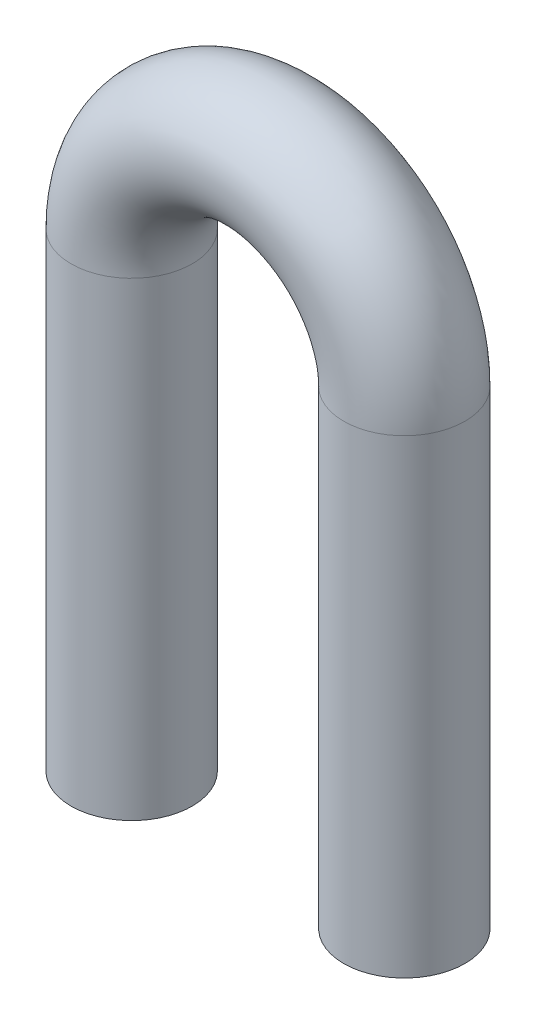
from build123d import *

# Parameters (mm, degrees)
SKETCH2_R = 2


with BuildPart() as part:
    # Sweep1: sweep along a path in Sketch1
    with BuildLine(Plane.XY) as sweep1_path:
        Line((0, 0), (0, 15.5))
        ThreePointArc((0, 15.5), (4.5, 20), (9, 15.5))
        Line((9, 15.5), (9, 0))
    # Sketch2 → Sweep1 (sweep)
    with BuildSketch(Plane(origin=(0, 0, 0), x_dir=(1, 0, 0), z_dir=(0, 1, 0))):
        Circle(SKETCH2_R)
    sweep(path=sweep1_path.line)


solid = part.part
